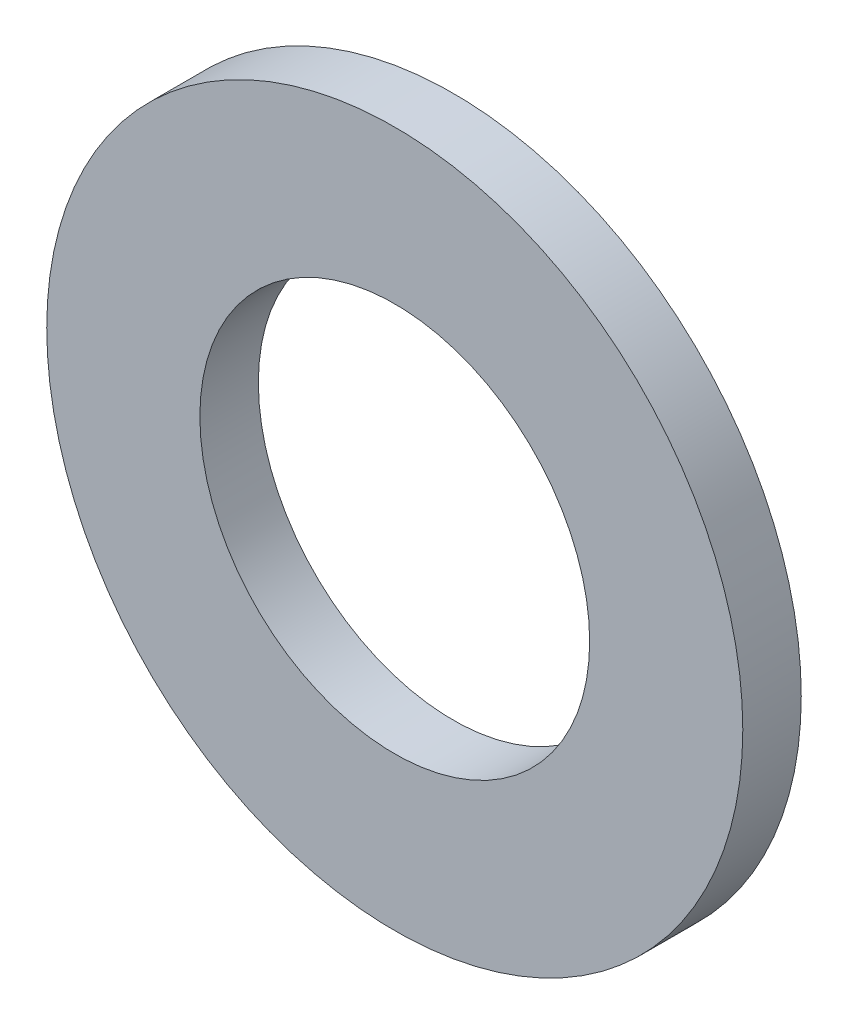
from build123d import *

# Parameters (mm, degrees)
SKETCH1_R           = 12.5
SKETCH1_R_2         = 7
BOSS_EXTRUDE1_DEPTH = 2.1


with BuildPart() as part:
    # Sketch1 → Boss-Extrude1 (new body)
    with BuildSketch(Plane.XY):
        Circle(SKETCH1_R)
        Circle(SKETCH1_R_2, mode=Mode.SUBTRACT)
    extrude(amount=BOSS_EXTRUDE1_DEPTH)


solid = part.part
